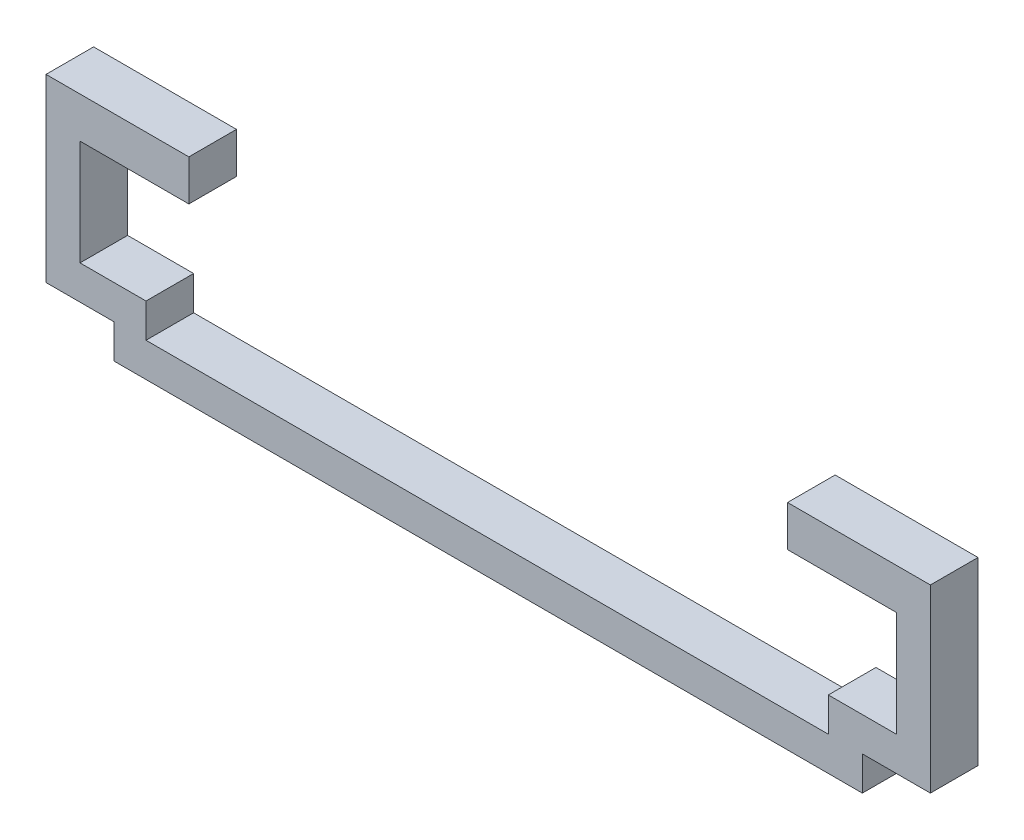
from build123d import *

# Parameters (mm, degrees)
SKETCH_1_W          = 100
SKETCH_1_H          = 5
EXTRUDE_1_DEPTH     = 8.8
SKETCH_2_W          = 5
SKETCH_2_H          = 10
EXTRUDE_2_DEPTH     = 8.8
SKETCH_3_W          = 5
SKETCH_3_H          = 10
EXTRUDE_3_DEPTH     = 8.8
SKETCH_4_W          = 5
SKETCH_4_H          = 5
EXTRUDE_4_DEPTH     = 8.8
SKETCH_5_W          = 5
SKETCH_5_H          = 5
EXTRUDE_5_DEPTH     = 8.8
SKETCH_6_W          = 0.3
SKETCH_6_H          = 5
CUT_EXTRUDE_1_DEPTH = 8.8
SKETCH_7_W          = 5
SKETCH_7_H          = 20.5
EXTRUDE_6_DEPTH     = 8.8
SKETCH_8_W          = 5
SKETCH_8_H          = 20.5
EXTRUDE_7_DEPTH     = 8.8
SKETCH_9_W          = 15
SKETCH_9_H          = 6
EXTRUDE_8_DEPTH     = 8.8
SKETCH_10_W         = 15
SKETCH_10_H         = 6
EXTRUDE_9_DEPTH     = 8.8
SKETCH_11_W         = 1.5
SKETCH_11_H         = 1.5
EXTRUDE_10_DEPTH    = 8.8
SKETCH_12_W         = 1.5
SKETCH_12_H         = 1.5
EXTRUDE_11_DEPTH    = 8.8
CUT_EXTRUDE_2_DEPTH = 1.8
SKETCH_15_W         = 1.5
SKETCH_15_H         = 1.5
CUT_EXTRUDE_3_DEPTH = 10
SKETCH_16_W         = 1.5
SKETCH_16_H         = 1.5
CUT_EXTRUDE_4_DEPTH = 10
SKETCH_17_W         = 7
SKETCH_17_H         = 6
EXTRUDE_12_DEPTH    = 5
SKETCH_18_W         = 7
SKETCH_18_H         = 6
EXTRUDE_13_DEPTH    = 5
SKETCH_19_W         = 7
SKETCH_19_H         = 6
EXTRUDE_14_DEPTH    = 1
SKETCH_20_W         = 7
SKETCH_20_H         = 6
EXTRUDE_15_DEPTH    = 1


with BuildPart() as part:
    # 草图1 → 凸台-拉伸1 (new body)
    with BuildSketch(Plane.XY):
        Rectangle(SKETCH_1_W, SKETCH_1_H)
    extrude(amount=EXTRUDE_1_DEPTH)

    # 草图2 → 凸台-拉伸2 (add)
    with BuildSketch(Plane(origin=(0, 0, 0), x_dir=(-1, 0, 0), z_dir=(0, 0, -1))):
        with Locations((-52.5, 2.5)):
            Rectangle(SKETCH_2_W, SKETCH_2_H)
    extrude(amount=-EXTRUDE_2_DEPTH)

    # 草图3 → 凸台-拉伸3 (add)
    with BuildSketch(Plane(origin=(0, 0, 0), x_dir=(-1, 0, 0), z_dir=(0, 0, -1))):
        with Locations((52.5, 2.5)):
            Rectangle(SKETCH_3_W, SKETCH_3_H)
    extrude(amount=-EXTRUDE_3_DEPTH)

    # 草图4 → 凸台-拉伸4 (add)
    with BuildSketch(Plane.XY.offset(8.8)):
        with Locations((-57.5, 5)):
            Rectangle(SKETCH_4_W, SKETCH_4_H)
    extrude(amount=-EXTRUDE_4_DEPTH)

    # 草图5 → 凸台-拉伸5 (add)
    with BuildSketch(Plane.XY.offset(8.8)):
        with Locations((57.5, 5)):
            Rectangle(SKETCH_5_W, SKETCH_5_H)
    extrude(amount=-EXTRUDE_5_DEPTH)

    # 草图6 → 切除-拉伸1 (cut)
    with BuildSketch(Plane.XY.offset(8.8)):
        with Locations((-50.15, 5)):
            Rectangle(SKETCH_6_W, SKETCH_6_H)
    extrude(amount=-CUT_EXTRUDE_1_DEPTH, mode=Mode.SUBTRACT)

    # 草图7 → 凸台-拉伸6 (add)
    with BuildSketch(Plane.XY.offset(8.8)):
        with Locations((-62.5, 12.75)):
            Rectangle(SKETCH_7_W, SKETCH_7_H)
    extrude(amount=-EXTRUDE_6_DEPTH)

    # 草图8 → 凸台-拉伸7 (add)
    with BuildSketch(Plane.XY.offset(8.8)):
        with Locations((62.5, 12.75)):
            Rectangle(SKETCH_8_W, SKETCH_8_H)
    extrude(amount=-EXTRUDE_7_DEPTH)

    # 草图9 → 凸台-拉伸8 (add)
    with BuildSketch(Plane.XY.offset(8.8)):
        with Locations((-57.5, 26)):
            Rectangle(SKETCH_9_W, SKETCH_9_H)
    extrude(amount=-EXTRUDE_8_DEPTH)

    # 草图10 → 凸台-拉伸9 (add)
    with BuildSketch(Plane.XY.offset(8.8)):
        with Locations((57.5, 26)):
            Rectangle(SKETCH_10_W, SKETCH_10_H)
    extrude(amount=-EXTRUDE_9_DEPTH)

    # 草图11 → 凸台-拉伸10 (add)
    with BuildSketch(Plane.XY.offset(8.8)):
        with Locations((-50.75, 22.25)):
            Rectangle(SKETCH_11_W, SKETCH_11_H)
    extrude(amount=-EXTRUDE_10_DEPTH)

    # 草图12 → 凸台-拉伸11 (add)
    with BuildSketch(Plane.XY.offset(8.8)):
        with Locations((50.75, 22.25)):
            Rectangle(SKETCH_12_W, SKETCH_12_H)
    extrude(amount=-EXTRUDE_11_DEPTH)

    # 草图14 → 切除-拉伸2 (cut)
    with BuildSketch(Plane.XY.offset(8.8)):
        Polygon((-51.5, 23), (-51.5, 21.5), (-50, 21.5), (-50, 29), (-65, 29), (-65, 2.5), (-55, 2.5), (-55, -2.5), (55, -2.5), (55, 2.5), (65, 2.5), (65, 29), (50, 29), (50, 21.5), (51.5, 21.5), (51.5, 23), (60, 23), (60, 7.5), (50, 7.5), (50, 2.5), (-50.3, 2.5), (-50.3, 7.5), (-60, 7.5), (-60, 23), align=None)
    extrude(amount=-CUT_EXTRUDE_2_DEPTH, mode=Mode.SUBTRACT)

    # 草图15 → 切除-拉伸3 (cut)
    with BuildSketch(Plane.XY.offset(7)):
        with Locations((-50.75, 22.25)):
            Rectangle(SKETCH_15_W, SKETCH_15_H)
    extrude(amount=-CUT_EXTRUDE_3_DEPTH, mode=Mode.SUBTRACT)

    # 草图16 → 切除-拉伸4 (cut)
    with BuildSketch(Plane.XY.offset(7)):
        with Locations((50.75, 22.25)):
            Rectangle(SKETCH_16_W, SKETCH_16_H)
    extrude(amount=-CUT_EXTRUDE_4_DEPTH, mode=Mode.SUBTRACT)

    # 草图17 → 凸台-拉伸12 (add)
    with BuildSketch(Plane(origin=(-50, 0, 0), x_dir=(0, 0, -1), z_dir=(1, 0, 0))):
        with Locations((-3.5, 26)):
            Rectangle(SKETCH_17_W, SKETCH_17_H)
    extrude(amount=EXTRUDE_12_DEPTH)

    # 草图18 → 凸台-拉伸13 (add)
    with BuildSketch(Plane.ZY.offset(-50)):
        with Locations((3.5, 26)):
            Rectangle(SKETCH_18_W, SKETCH_18_H)
    extrude(amount=EXTRUDE_13_DEPTH)

    # 草图19 → 凸台-拉伸14 (add)
    with BuildSketch(Plane(origin=(-45, 0, 0), x_dir=(0, 0, -1), z_dir=(1, 0, 0))):
        with Locations((-3.5, 26)):
            Rectangle(SKETCH_19_W, SKETCH_19_H)
    extrude(amount=EXTRUDE_14_DEPTH)

    # 草图20 → 凸台-拉伸15 (add)
    with BuildSketch(Plane.ZY.offset(-45)):
        with Locations((3.5, 26)):
            Rectangle(SKETCH_20_W, SKETCH_20_H)
    extrude(amount=EXTRUDE_15_DEPTH)


solid = part.part
